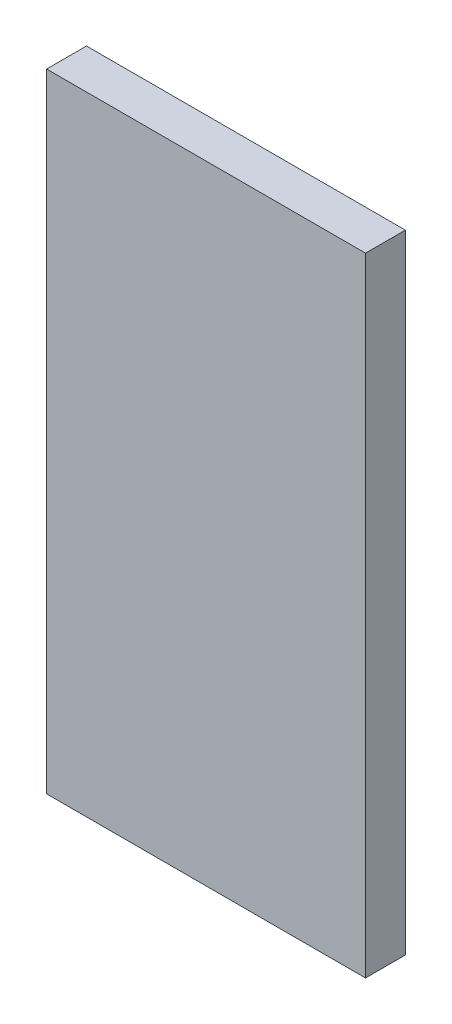
from build123d import *

# Parameters (mm, degrees)
SKETCH1_W           = 50.8
SKETCH1_H           = 100
BOSS_EXTRUDE1_DEPTH = 6.35


with BuildPart() as part:
    # Sketch1 → Boss-Extrude1 (new body)
    with BuildSketch(Plane.XY):
        with Locations((25.4, -50)):
            Rectangle(SKETCH1_W, SKETCH1_H)
    extrude(amount=BOSS_EXTRUDE1_DEPTH)


solid = part.part
